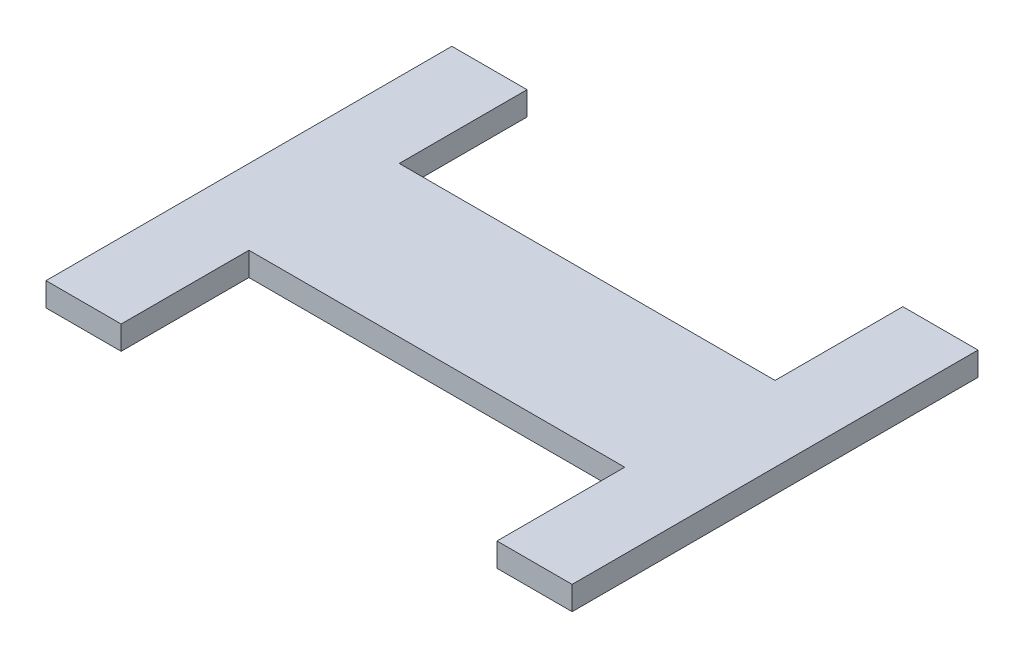
from build123d import *

# Parameters (mm, degrees)
SKETCH1_W               = 88.9
SKETCH1_H               = 25.4
BOSS_EXTRUDE1_DEPTH     = 4
MIRROR3_COPY_1_SKETCH_W = 88.9
MIRROR3_COPY_1_SKETCH_H = 25.4
MIRROR3_COPY_1_DEPTH    = 4


with BuildPart() as part:
    # Sketch1 → Boss-Extrude1 (new body)
    with BuildSketch(Plane(origin=(0, 0, 0), x_dir=(1, 0, 0), z_dir=(0, 1, 0))):
        Rectangle(SKETCH1_W, SKETCH1_H)
        Polygon((-44.45, 34.29), (-44.45, 12.7), (-31.75, 12.7), (-31.75, 34.29), (-38.1, 34.29), align=None)
    boss_extrude1 = extrude(amount=BOSS_EXTRUDE1_DEPTH)

    # Mirror1: Boss-Extrude1 across plane
    add(boss_extrude1.mirror(Plane.ZY))

    # Mirror2: Boss-Extrude1 across plane
    add(boss_extrude1.mirror(Plane.XY))

    # Mirror3: Boss-Extrude1 across plane
    add(boss_extrude1.mirror(Plane.ZY))

    # Mirror3 copy 1 sketch → Mirror3 copy 1 (add)
    with BuildSketch(Plane(origin=(0, 0, 0), x_dir=(-1, 0, 0), z_dir=(0, 1, 0))):
        Rectangle(MIRROR3_COPY_1_SKETCH_W, MIRROR3_COPY_1_SKETCH_H)
        Polygon((-44.45, 34.29), (-44.45, 12.7), (-31.75, 12.7), (-31.75, 34.29), (-38.1, 34.29), align=None)
    extrude(amount=MIRROR3_COPY_1_DEPTH)


solid = part.part
